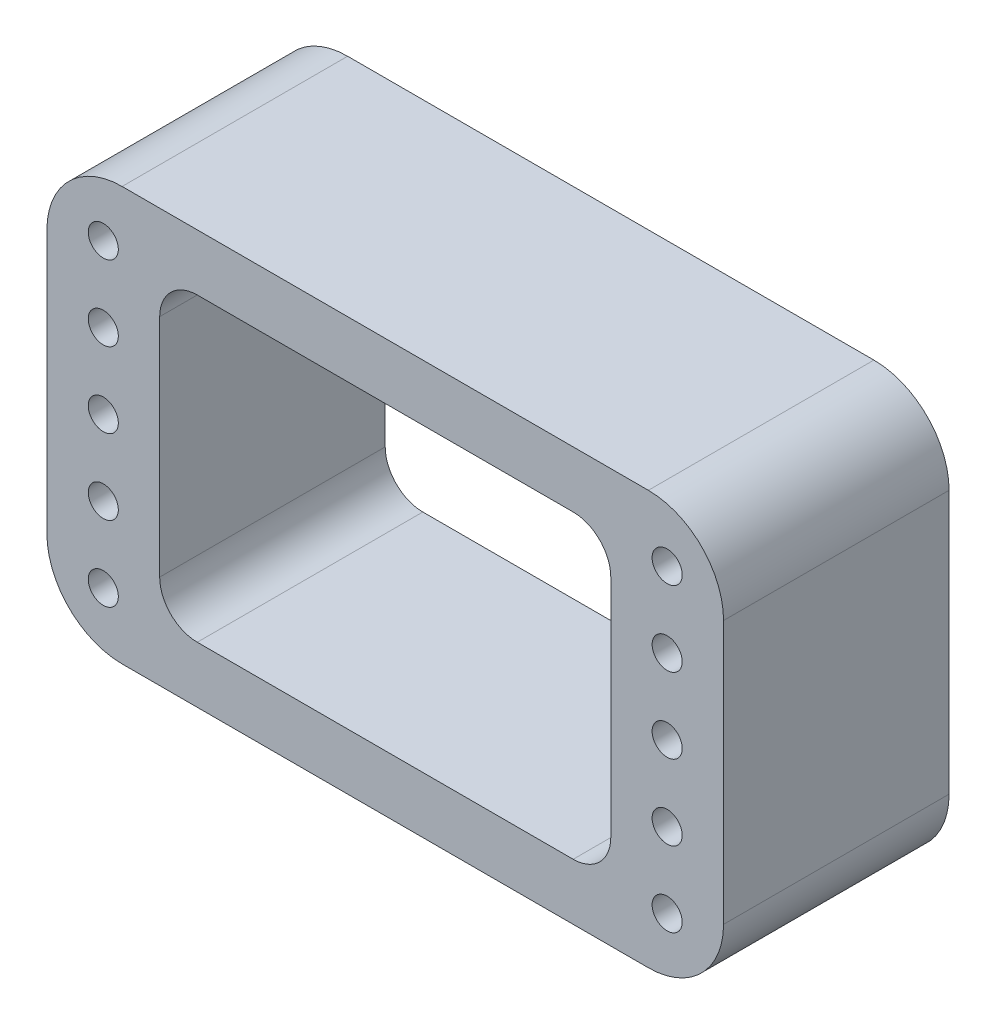
from build123d import *

# Parameters (mm, degrees)
SKETCH1_W           = 90
SKETCH1_H           = 55
BOSS_EXTRUDE1_DEPTH = 30
SKETCH2_W           = 60
SKETCH2_H           = 40
CUT_EXTRUDE1_DEPTH  = 31
SKETCH3_R           = 2
CUT_EXTRUDE2_DEPTH  = 31
LPATTERN1_COUNT     = 3
LPATTERN1_PITCH     = 10
LPATTERN1_COL_COUNT = 3
LPATTERN1_COL_PITCH = 10
FILLET1_R           = 10
FILLET2_R           = 5


with BuildPart() as part:
    # Sketch1 → Boss-Extrude1 (new body)
    with BuildSketch(Plane.XY):
        Rectangle(SKETCH1_W, SKETCH1_H)
    extrude(amount=BOSS_EXTRUDE1_DEPTH)

    # Sketch2 → Cut-Extrude1 (cut, through all)
    with BuildSketch(Plane.XY.offset(30)):
        Rectangle(SKETCH2_W, SKETCH2_H)
    extrude(amount=-CUT_EXTRUDE1_DEPTH, mode=Mode.SUBTRACT)

    # Sketch3 → Cut-Extrude2 (cut, through all)
    with BuildSketch(Plane(origin=(0, 0, 0), x_dir=(-1, 0, 0), z_dir=(0, 0, -1))):
        with Locations((-37.5, 0)):
            Circle(SKETCH3_R)
        with Locations((37.5, 0)):
            Circle(SKETCH3_R)
    cut_extrude2 = extrude(amount=-CUT_EXTRUDE2_DEPTH, mode=Mode.SUBTRACT)

    # LPattern1: Cut-Extrude2 ×3
    with Locations(*[(0, -i * LPATTERN1_PITCH, 0) for i in range(1, LPATTERN1_COUNT)]):
        add(cut_extrude2, mode=Mode.SUBTRACT)

    # LPattern1 col: Cut-Extrude2 ×3
    with Locations(*[(0, i * LPATTERN1_COL_PITCH, 0) for i in range(1, LPATTERN1_COL_COUNT)]):
        add(cut_extrude2, mode=Mode.SUBTRACT)

    # Fillet1
    fillet1_edges = [part.edges().sort_by_distance(p)[0] for p in [
        (45, -27.5, 15),
        (-45, -27.5, 15),
        (-45, 27.5, 15),
        (45, 27.5, 15),
    ]]
    fillet(fillet1_edges, radius=FILLET1_R)

    # Fillet2
    fillet2_edges = [part.edges().sort_by_distance(p)[0] for p in [
        (30, 20, 15),
        (30, -20, 15),
        (-30, -20, 15),
        (-30, 20, 15),
    ]]
    fillet(fillet2_edges, radius=FILLET2_R)


solid = part.part
